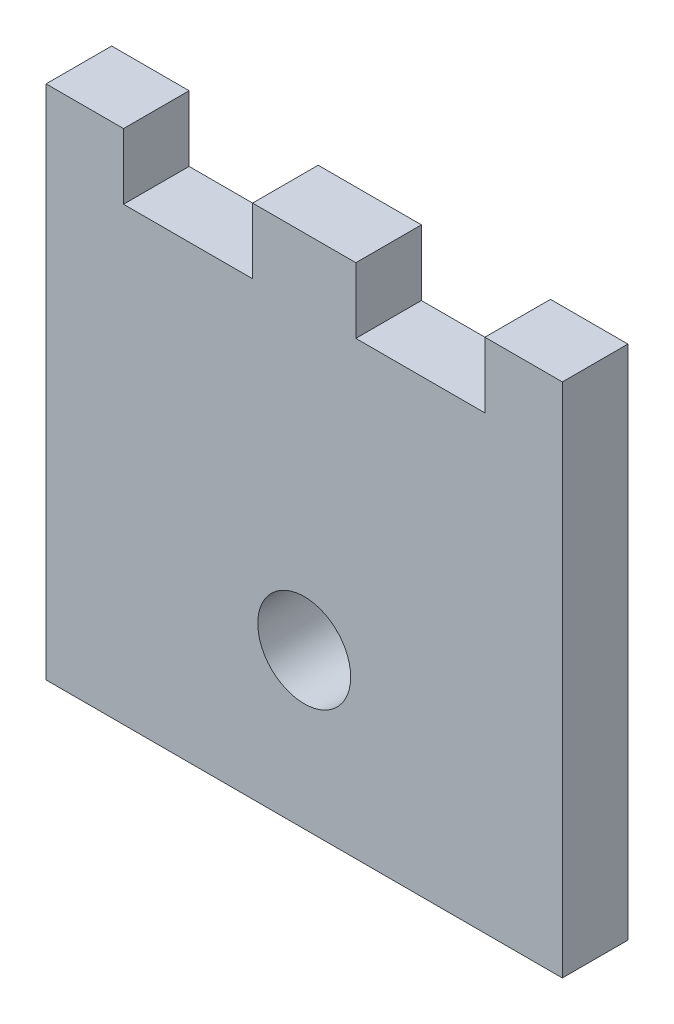
from build123d import *

# Parameters (mm, degrees)
SKETCH1_W           = 50
SKETCH1_H           = 50
BOSS_EXTRUDE1_DEPTH = 6.35
SKETCH4_R           = 4.5
SKETCH4_W           = 12.5
SKETCH4_H           = 6.35
CUT_EXTRUDE1_DEPTH  = 6.35


with BuildPart() as part:
    # Sketch1 → Boss-Extrude1 (new body)
    with BuildSketch(Plane.XY):
        with Locations((25, 25)):
            Rectangle(SKETCH1_W, SKETCH1_H)
    extrude(amount=BOSS_EXTRUDE1_DEPTH)

    # Sketch4 → Cut-Extrude1 (cut)
    with BuildSketch(Plane.XY.offset(6.35)):
        with Locations((25, 15)):
            Circle(SKETCH4_R)
        with Locations((13.75, 46.825)):
            Rectangle(SKETCH4_W, SKETCH4_H)
        with Locations((36.25, 46.825)):
            Rectangle(SKETCH4_W, SKETCH4_H)
    extrude(amount=-CUT_EXTRUDE1_DEPTH, mode=Mode.SUBTRACT)


solid = part.part
